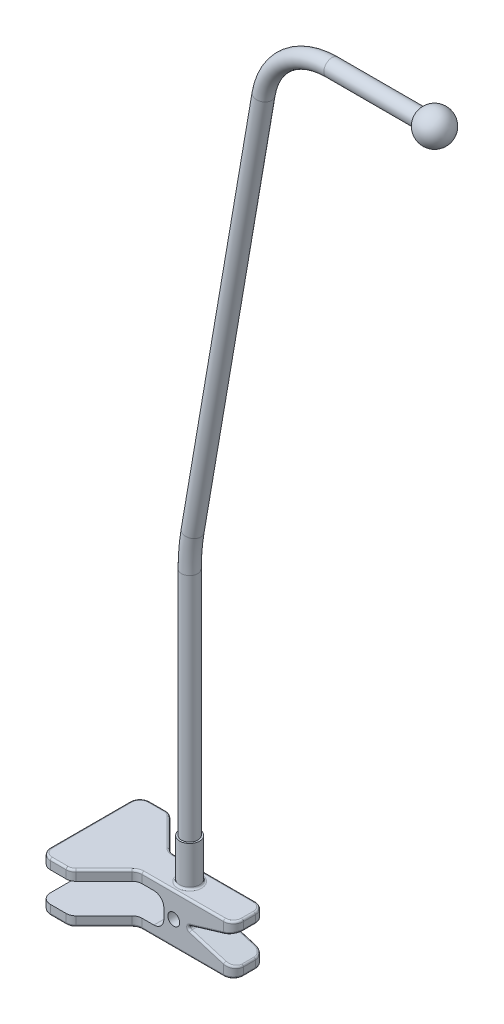
from build123d import *

# Parameters (mm, degrees)
CROQUIS1_R              = 5
SALIENTE_EXTRUIR1_DEPTH = 20
SALIENTE_EXTRUIR2_DEPTH = 25
CORTAR_EXTRUIR1_DEPTH   = 26
REDONDEO1_R             = 5
REDONDEO2_R             = 1
CROQUIS4_R              = 4.125
CROQUIS7_R              = 3
CORTAR_EXTRUIR2_DEPTH   = 34


with BuildPart() as part:
    # Croquis1 → Saliente-Extruir1 (new body)
    with BuildSketch(Plane(origin=(0, 0, 0), x_dir=(1, 0, 0), z_dir=(0, 1, 0))):
        Circle(CROQUIS1_R)
    extrude(amount=SALIENTE_EXTRUIR1_DEPTH)

    # Croquis2 → Saliente-Extruir2 (add, symmetric)
    with BuildSketch(Plane.XY):
        Polygon((30, 0), (-50, 0), (-50, -5), (-5, -5), (-5, -20), (-50, -20), (-50, -25), (30, -25), (30, -20), (5, -12.5), (30, -5), align=None)
    extrude(amount=SALIENTE_EXTRUIR2_DEPTH, both=True)

    # Croquis3 → Cortar-Extruir1 (cut, through all)
    with BuildSketch(Plane(origin=(0, 0, 0), x_dir=(1, 0, 0), z_dir=(0, 1, 0))):
        Polygon((-35, -25), (-18, -8), (30, -8), (30, -25), align=None)
        Polygon((30, 8), (30, 25), (-35, 25), (-18, 8), align=None)
    extrude(amount=-CORTAR_EXTRUIR1_DEPTH, mode=Mode.SUBTRACT)

    # Redondeo1
    redondeo1_edges = [part.edges().sort_by_distance(p)[0] for p in [
        (-50, -2.5, 25),
        (-50, -22.5, 25),
        (-35, -2.5, -25),
        (-35, -2.5, 25),
        (-5, -20, 0),
        (-5, -5, 0),
        (-18, -2.5, 8),
        (-18, -22.5, 8),
        (-35, -22.5, 25),
        (30, -22.5, 8),
        (30, -2.5, 8),
        (-50, -2.5, -25),
        (30, -22.5, -8),
        (30, -2.5, -8),
        (-35, -22.5, -25),
        (-18, -2.5, -8),
        (-18, -22.5, -8),
        (-50, -22.5, -25),
    ]]
    fillet(redondeo1_edges, radius=REDONDEO1_R)

    # Redondeo2
    redondeo2_edges = [part.edges().sort_by_distance(p)[0] for p in [
        (-26.5, -25, 16.5),
        (4.535533906, -25, 8),
        (15, -9.5, 8),
        (4.535533906, 0, 8),
        (-26.5, 0, 16.5),
        (4.535533906, 0, -8),
        (15, -15.5, -8),
        (4.535533906, -25, -8),
        (-26.5, -25, -16.5),
        (-26.5, 0, -16.5),
        (-41.035533906, -25, -25),
        (-41.035533906, -25, 25),
        (-50, -25, 0),
        (30, -25, 0),
        (-35.15765065, -25, 24.619397663),
        (-48.535533906, -25, 23.535533906),
        (28.535533906, -25, 6.535533906),
        (28.535533906, -25, -6.535533906),
        (-48.535533906, -25, -23.535533906),
        (-35.15765065, -25, -24.619397663),
        (-41.035533906, 0, 25),
        (30, 0, 0),
        (-41.035533906, 0, -25),
        (-50, 0, 0),
        (-48.535533906, 0, 23.535533906),
        (-48.535533906, 0, -23.535533906),
        (-35.15765065, 0, 24.619397663),
        (28.535533906, 0, 6.535533906),
        (28.535533906, 0, -6.535533906),
        (-35.15765065, 0, -24.619397663),
        (30, -5, 0),
        (28.497270762, -5.450818772, 6.573387359),
        (28.497270762, -5.450818772, -6.573387359),
        (30, -20, 0),
        (28.497270762, -19.549181228, 6.573387359),
        (28.497270762, -19.549181228, -6.573387359),
        (-17.84234935, -25, 8.380602337),
        (-17.84234935, 0, 8.380602337),
        (-17.84234935, -25, -8.380602337),
        (-17.84234935, 0, -8.380602337),
        (5, -12.5, 0),
        (15, -9.5, -8),
        (-5, 0, 0),
        (15, -15.5, 8),
    ]]
    fillet(redondeo2_edges, radius=REDONDEO2_R)

    # Barrer1: sweep along a path in Croquis5
    with BuildLine(Plane.XY) as barrer1_path:
        Line((0, 20), (0, 135.938556576))
        ThreePointArc((0, 135.938556576), (0.368873619, 144.620786193), (1.472835915, 153.240440832))
        Line((1.472835915, 153.240440832), (37.105688479, 361.019179369))
        ThreePointArc((37.105688479, 361.019179369), (48.999329121, 381.787970979), (71.479630988, 390))
        Line((71.479630988, 390), (123, 390))
    # Croquis4 → Barrer1 (sweep)
    with BuildSketch(Plane(origin=(0, 20, 0), x_dir=(1, 0, 0), z_dir=(0, 1, 0))):
        Circle(CROQUIS4_R)
    sweep(path=barrer1_path.line)

    # Croquis6 → Revolución1 (revolve)
    with BuildSketch(Plane.XY):
        with BuildLine():
            Line((123, 390), (123, 381.75))
            ThreePointArc((123, 381.75), (131.25, 390), (123, 398.25))
            Line((123, 398.25), (123, 390))
        make_face()
    revolve(axis=Axis((123, 398.25, 0), (0, -1, 0)))

    # Croquis7 → Cortar-Extruir2 (cut, through all)
    with BuildSketch(Plane.XY.offset(8)):
        with Locations((0, -12.5)):
            Circle(CROQUIS7_R)
    extrude(amount=-CORTAR_EXTRUIR2_DEPTH, mode=Mode.SUBTRACT)


solid = part.part
